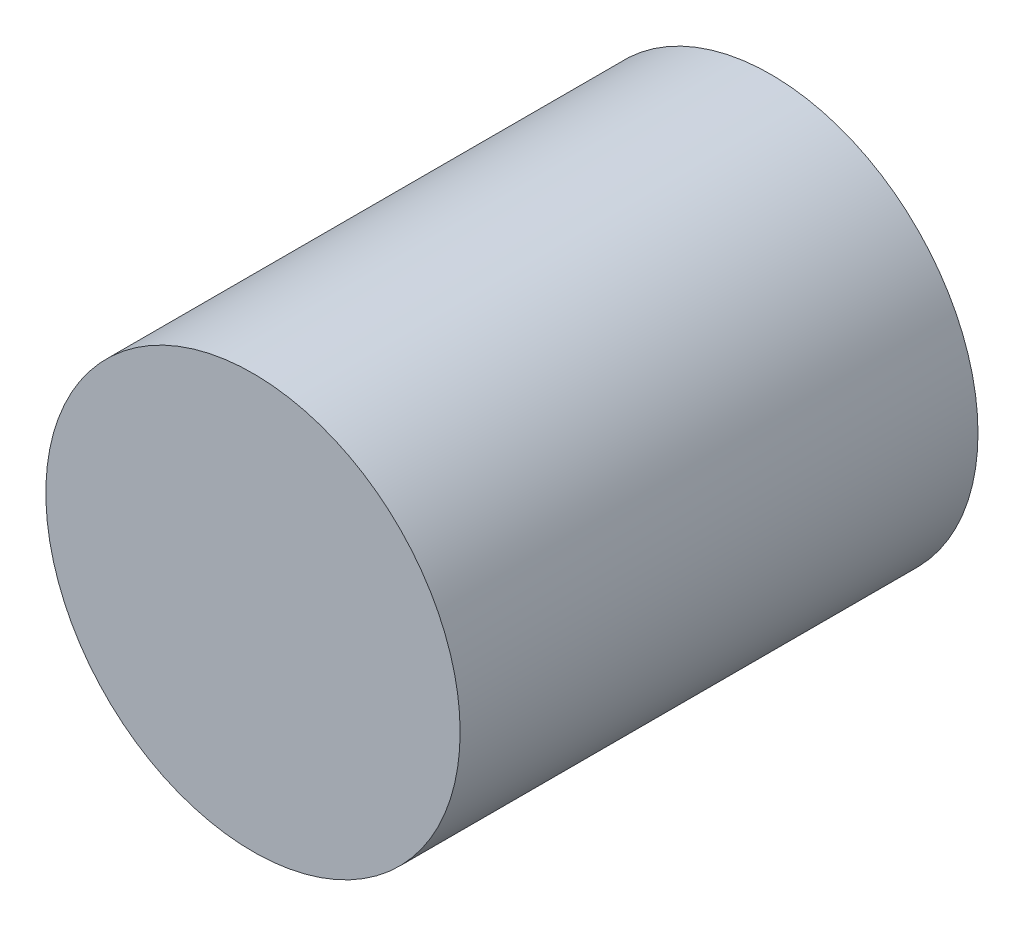
from build123d import *

# Parameters (mm, degrees)
SKETCH1_R           = 20
BOSS_EXTRUDE1_DEPTH = 50


with BuildPart() as part:
    # Sketch1 → Boss-Extrude1 (new body)
    with BuildSketch(Plane.XY):
        Circle(SKETCH1_R)
    extrude(amount=BOSS_EXTRUDE1_DEPTH)


solid = part.part
